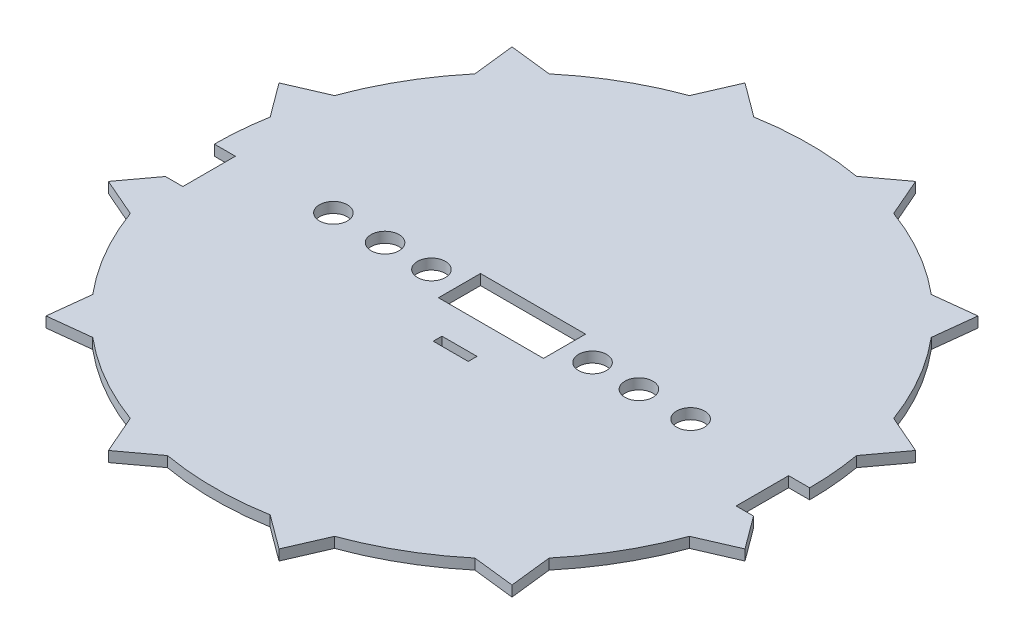
from build123d import *

# Parameters (mm, degrees)
EXTRUDE1_DEPTH = 0.3
SKETCH3_R      = 0.4
SKETCH3_W      = 3
SKETCH3_H      = 1.2
EXTRUDE2_DEPTH = 1.3
SKETCH4_W      = 1
SKETCH4_H      = 0.25
EXTRUDE3_DEPTH = 24
SKETCH5_W      = 1.5
SKETCH5_H      = 1.5
EXTRUDE5_DEPTH = 1


with BuildPart() as part:
    # Sketch1 → Extrude1 (new body)
    with BuildSketch(Plane(origin=(0, 0, 0), x_dir=(1, 0, 0), z_dir=(0, 1, 0))):
        with BuildLine():
            Line((-2.435487214, 9.089362025), (-2.915825654, 7.984232008))
            ThreePointArc((-2.915825654, 7.984232008), (-4.25, 7.361215932), (-5.456634922, 6.517295093))
            Line((-5.456634922, 6.517295093), (-6.653874811, 6.653874811))
            Line((-6.653874811, 6.653874811), (-6.517295093, 5.456634922))
            ThreePointArc((-6.517295093, 5.456634922), (-7.361215932, 4.25), (-7.984232008, 2.915825654))
            Line((-7.984232008, 2.915825654), (-9.089362025, 2.435487214))
            Line((-9.089362025, 2.435487214), (-8.372460576, 1.466936915))
            ThreePointArc((-8.372460576, 1.466936915), (-8.5, 0), (-8.372460576, -1.466936915))
            Line((-8.372460576, -1.466936915), (-9.089362025, -2.435487214))
            Line((-9.089362025, -2.435487214), (-7.984232008, -2.915825654))
            ThreePointArc((-7.984232008, -2.915825654), (-7.361215932, -4.25), (-6.517295093, -5.456634922))
            Line((-6.517295093, -5.456634922), (-6.653874811, -6.653874811))
            Line((-6.653874811, -6.653874811), (-5.456634922, -6.517295093))
            ThreePointArc((-5.456634922, -6.517295093), (-4.25, -7.361215932), (-2.915825654, -7.984232008))
            Line((-2.915825654, -7.984232008), (-2.435487214, -9.089362025))
            Line((-2.435487214, -9.089362025), (-1.466936915, -8.372460576))
            ThreePointArc((-1.466936915, -8.372460576), (0, -8.5), (1.466936915, -8.372460576))
            Line((1.466936915, -8.372460576), (2.435487214, -9.089362025))
            Line((2.435487214, -9.089362025), (2.915825654, -7.984232008))
            ThreePointArc((2.915825654, -7.984232008), (4.25, -7.361215932), (5.456634922, -6.517295093))
            Line((5.456634922, -6.517295093), (6.653874811, -6.653874811))
            Line((6.653874811, -6.653874811), (6.517295093, -5.456634922))
            ThreePointArc((6.517295093, -5.456634922), (7.361215932, -4.25), (7.984232008, -2.915825654))
            Line((7.984232008, -2.915825654), (9.089362025, -2.435487214))
            Line((9.089362025, -2.435487214), (8.372460576, -1.466936915))
            ThreePointArc((8.372460576, -1.466936915), (8.5, 0), (8.372460576, 1.466936915))
            Line((8.372460576, 1.466936915), (9.089362025, 2.435487214))
            Line((9.089362025, 2.435487214), (7.984232008, 2.915825654))
            ThreePointArc((7.984232008, 2.915825654), (7.361215932, 4.25), (6.517295093, 5.456634922))
            Line((6.517295093, 5.456634922), (6.653874811, 6.653874811))
            Line((6.653874811, 6.653874811), (5.456634922, 6.517295093))
            ThreePointArc((5.456634922, 6.517295093), (4.25, 7.361215932), (2.915825654, 7.984232008))
            Line((2.915825654, 7.984232008), (2.435487214, 9.089362025))
            Line((2.435487214, 9.089362025), (1.466936915, 8.372460576))
            ThreePointArc((1.466936915, 8.372460576), (0, 8.5), (-1.466936915, 8.372460576))
            Line((-1.466936915, 8.372460576), (-2.435487214, 9.089362025))
        make_face()
    extrude(amount=EXTRUDE1_DEPTH)

    # Sketch3 → Extrude2 (cut, through all)
    with BuildSketch(Plane(origin=(0, 0, 0), x_dir=(1, 0, 0), z_dir=(0, 1, 0))):
        with Locations((-2.3, 0)):
            Circle(SKETCH3_R)
        with Locations((-3.625, 0)):
            Circle(SKETCH3_R)
        with Locations((-5.1, 0)):
            Circle(SKETCH3_R)
        with Locations((2.3, 0)):
            Circle(SKETCH3_R)
        with Locations((3.625, 0)):
            Circle(SKETCH3_R)
        with Locations((5.1, 0)):
            Circle(SKETCH3_R)
        Rectangle(SKETCH3_W, SKETCH3_H)
    extrude(amount=EXTRUDE2_DEPTH, mode=Mode.SUBTRACT)

    # Sketch4 → Extrude3 (cut)
    with BuildSketch(Plane(origin=(0, 0, 0), x_dir=(1, 0, 0), z_dir=(0, 1, 0))):
        with Locations((0, -1.625)):
            Rectangle(SKETCH4_W, SKETCH4_H)
    extrude(amount=EXTRUDE3_DEPTH, mode=Mode.SUBTRACT)

    # Sketch5 → Extrude5 (cut)
    with BuildSketch(Plane(origin=(0, 0, 0), x_dir=(1, 0, 0), z_dir=(0, 1, 0))):
        with Locations((-8.65, -0.75)):
            Rectangle(SKETCH5_W, SKETCH5_H)
        with Locations((8.65, -0.75)):
            Rectangle(SKETCH5_W, SKETCH5_H)
    extrude(amount=EXTRUDE5_DEPTH, mode=Mode.SUBTRACT)


solid = part.part
